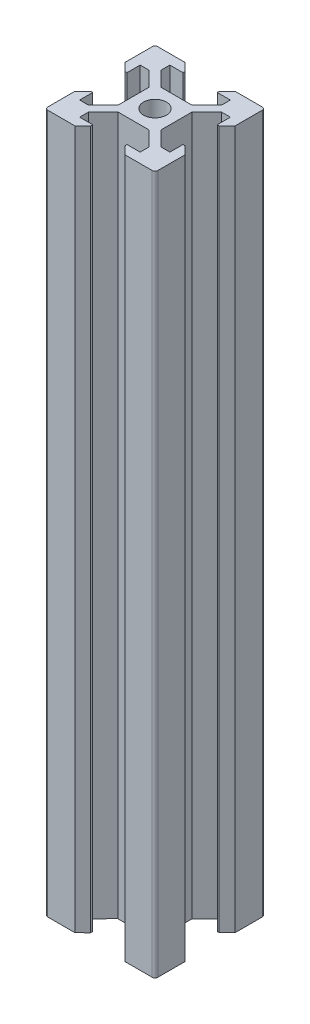
from build123d import *

# Parameters (mm, degrees)
SKETCH2_R              = 2.074585303
VSLOT2020_2020_5_DEPTH = 127


with BuildPart() as part:
    # Sketch2 → Vslot2020 2020(5) (new body)
    with BuildSketch(Plane.ZX):
        with BuildLine():
            Line((13.9, 7.149086807), (13.9, 12.844511469))
            Line((13.9, 12.844511469), (16.558493656, 15.492177728))
            Line((16.558493656, 15.492177728), (16.550703242, 15.5))
            Line((16.550703242, 15.5), (18.2, 15.5))
            Line((18.2, 15.5), (18.2, 13.12))
            Line((18.2, 13.12), (18.534428266, 13.12))
            Line((18.534428266, 13.12), (20, 14.58))
            Line((20, 14.58), (20, 19.5))
            ThreePointArc((20, 19.5), (19.853553391, 19.853553391), (19.5, 20))
            Line((19.5, 20), (14.575, 20))
            Line((14.575, 20), (13.12, 18.545))
            Line((13.12, 18.545), (13.12, 18.2))
            Line((13.12, 18.2), (15.5, 18.2))
            Line((15.5, 18.2), (15.5, 16.555))
            Line((15.5, 16.555), (12.834142613, 13.9))
            Line((12.834142613, 13.9), (7.155, 13.9))
            Line((7.155, 13.9), (4.5, 16.555))
            Line((4.5, 16.555), (4.5, 18.2))
            Line((4.5, 18.2), (6.875, 18.2))
            Line((6.875, 18.2), (6.875, 18.545))
            Line((6.875, 18.545), (5.42, 20))
            Line((5.42, 20), (0.5, 20))
            ThreePointArc((0.5, 20), (0.146446609, 19.853553391), (0, 19.5))
            Line((0, 19.5), (0, 14.58))
            Line((0, 14.58), (1.46, 13.12))
            Line((1.46, 13.12), (1.8, 13.12))
            Line((1.8, 13.12), (1.8, 15.5))
            Line((1.8, 15.5), (3.445, 15.5))
            Line((3.445, 15.5), (3.439339828, 15.494339828))
            Line((3.439339828, 15.494339828), (6.094339828, 12.839339828))
            Line((6.094339828, 12.839339828), (6.1, 12.845))
            Line((6.1, 12.845), (6.1, 7.149086807))
            Line((6.1, 7.149086807), (3.439339828, 4.5))
            Line((3.439339828, 4.5), (1.8, 4.5))
            Line((1.8, 4.5), (1.8, 6.88))
            Line((1.8, 6.88), (1.46, 6.88))
            Line((1.46, 6.88), (0, 5.42))
            Line((0, 5.42), (0, 0.5))
            ThreePointArc((0, 0.5), (0.146446609, 0.146446609), (0.5, 0))
            Line((0.5, 0), (5.42, 0))
            Line((5.42, 0), (6.875, 1.455))
            Line((6.875, 1.455), (6.875, 1.8))
            Line((6.875, 1.8), (4.5, 1.8))
            Line((4.5, 1.8), (4.5, 3.4393348))
            Line((4.5, 3.4393348), (7.158345795, 6.086117297))
            Line((7.158345795, 6.086117297), (7.144523479, 6.1))
            Line((7.144523479, 6.1), (12.854625295, 6.1))
            Line((12.854625295, 6.1), (12.841221344, 6.086548451))
            Line((12.841221344, 6.086548451), (15.499715, 3.437461644))
            Line((15.499715, 3.437461644), (15.5, 1.8))
            Line((15.5, 1.8), (13.12, 1.8))
            Line((13.12, 1.8), (13.12, 1.455))
            Line((13.12, 1.455), (14.575, 0))
            Line((14.575, 0), (19.5, 0))
            ThreePointArc((19.5, 0), (19.853553391, 0.146446609), (20, 0.5))
            Line((20, 0.5), (20, 5.42))
            Line((20, 5.42), (18.606904708, 6.88))
            Line((18.606904708, 6.88), (18.2, 6.88))
            Line((18.2, 6.88), (18.2, 4.5))
            Line((18.2, 4.5), (16.558493656, 4.5))
            Line((16.558493656, 4.5), (13.9, 7.149086807))
        make_face()
        with Locations((10, 10)):
            Circle(SKETCH2_R, mode=Mode.SUBTRACT)
    extrude(amount=VSLOT2020_2020_5_DEPTH)


solid = part.part
